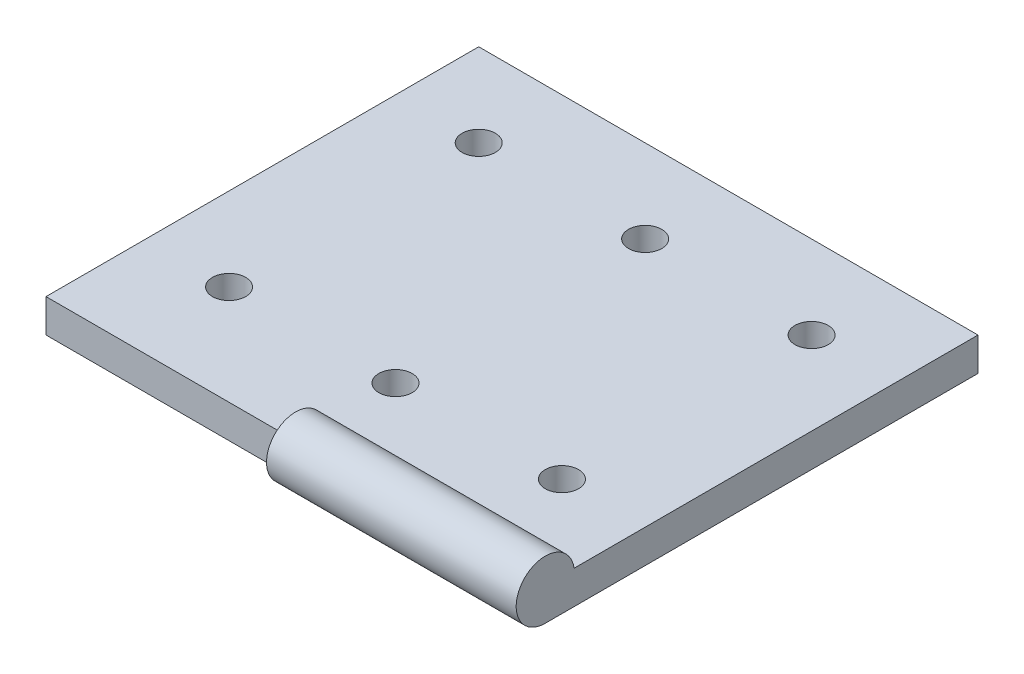
from build123d import *

# Parameters (mm, degrees)
SKETCH1_W           = 15
SKETCH1_H           = 13
BOSS_EXTRUDE1_DEPTH = 1
SKETCH2_R           = 0.875
BOSS_EXTRUDE2_DEPTH = 7.5
SKETCH3_R           = 0.5
CUT_EXTRUDE1_DEPTH  = 2


with BuildPart() as part:
    # Sketch1 → Boss-Extrude1 (new body)
    with BuildSketch(Plane(origin=(0, 0, 0), x_dir=(1, 0, 0), z_dir=(0, 1, 0))):
        with Locations((10.569631841, -166.54341444)):
            Rectangle(SKETCH1_W, SKETCH1_H)
    extrude(amount=BOSS_EXTRUDE1_DEPTH)

    # Sketch2 → Boss-Extrude2 (add)
    with BuildSketch(Plane(origin=(18.069631841, 0, 0), x_dir=(0, 0, -1), z_dir=(1, 0, 0))):
        with Locations((-173.04341444, 0.875)):
            Circle(SKETCH2_R)
    extrude(amount=-BOSS_EXTRUDE2_DEPTH)

    # Sketch3 → Cut-Extrude1 (cut, through all)
    with BuildSketch(Plane(origin=(0, 1, 0), x_dir=(1, 0, 0), z_dir=(0, 1, 0))):
        with Locations((15.569631841, -162.54341444)):
            Circle(SKETCH3_R)
        with Locations((15.569631841, -170.04341444)):
            Circle(SKETCH3_R)
        with Locations((10.569631841, -162.54341444)):
            Circle(SKETCH3_R)
        with Locations((10.569631841, -170.04341444)):
            Circle(SKETCH3_R)
        with Locations((5.569631841, -162.54341444)):
            Circle(SKETCH3_R)
        with Locations((5.569631841, -170.04341444)):
            Circle(SKETCH3_R)
    extrude(amount=-CUT_EXTRUDE1_DEPTH, mode=Mode.SUBTRACT)


solid = part.part
